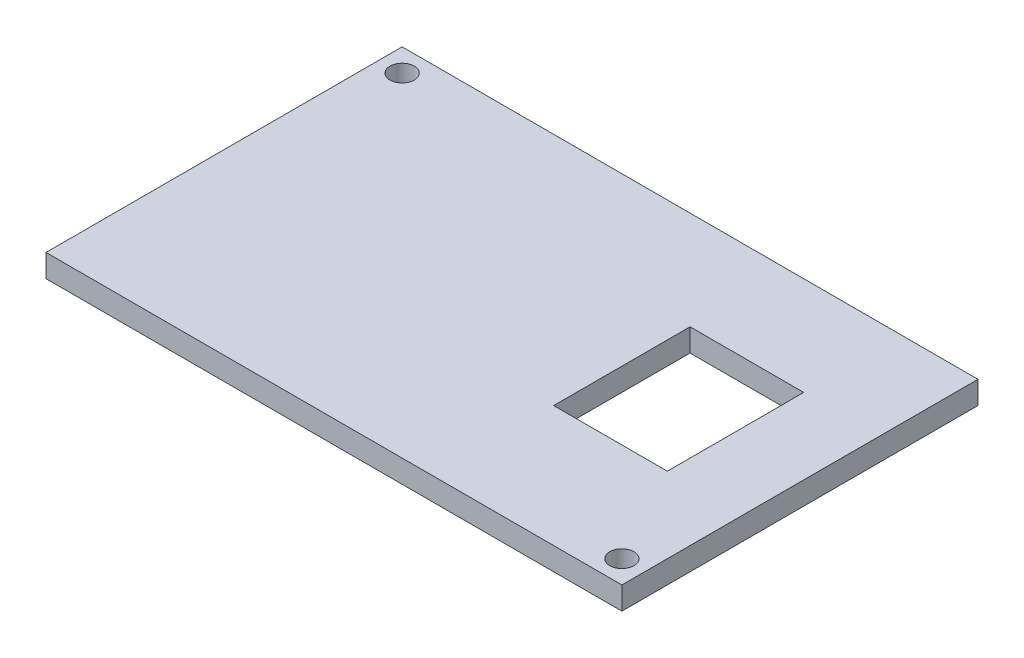
from build123d import *

# Parameters (mm, degrees)
SKETCH1_W           = 76
SKETCH1_H           = 47
BOSS_EXTRUDE2_DEPTH = 3
SKETCH2_R           = 1.6
CUT_EXTRUDE1_DEPTH  = 3
SKETCH3_W           = 15
SKETCH3_H           = 18
CUT_EXTRUDE3_DEPTH  = 3


with BuildPart() as part:
    # Sketch1 → Boss-Extrude2 (new body)
    with BuildSketch(Plane(origin=(0, 0, 0), x_dir=(1, 0, 0), z_dir=(0, 1, 0))):
        with Locations((-584.907023411, 237.380936455)):
            Rectangle(SKETCH1_W, SKETCH1_H)
    extrude(amount=BOSS_EXTRUDE2_DEPTH)

    # Sketch2 → Cut-Extrude1 (cut)
    with BuildSketch(Plane(origin=(0, 3, 0), x_dir=(1, 0, 0), z_dir=(0, 1, 0))):
        with Locations((-619.907023411, 257.880936455)):
            Circle(SKETCH2_R)
        with Locations((-549.907023411, 216.880936455)):
            Circle(SKETCH2_R)
    extrude(amount=-CUT_EXTRUDE1_DEPTH, mode=Mode.SUBTRACT)

    # Sketch3 → Cut-Extrude3 (cut)
    with BuildSketch(Plane(origin=(0, 3, 0), x_dir=(1, 0, 0), z_dir=(0, 1, 0))):
        with Locations((-564.407023411, 238.880936455)):
            Rectangle(SKETCH3_W, SKETCH3_H)
    extrude(amount=-CUT_EXTRUDE3_DEPTH, mode=Mode.SUBTRACT)


solid = part.part
